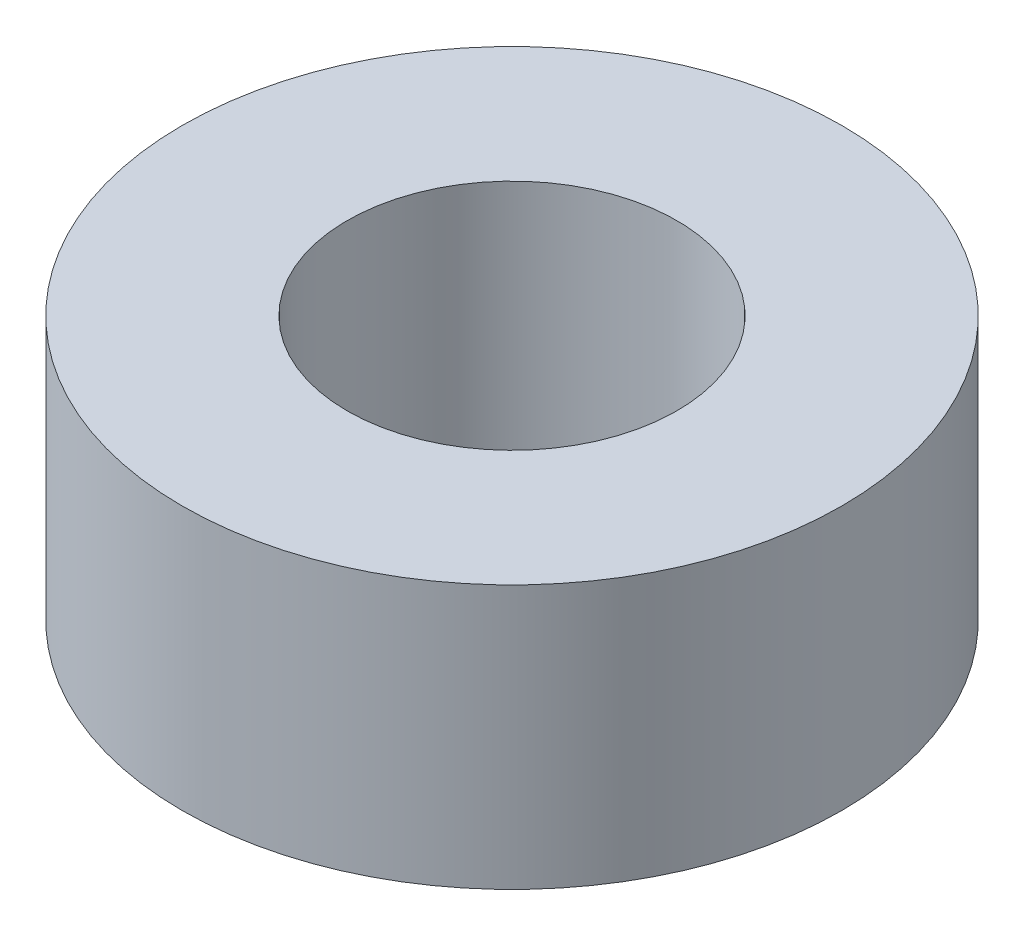
from build123d import *

# Parameters (mm, degrees)
SKETCH2_R           = 5
SKETCH2_R_2         = 2.5
BOSS_EXTRUDE1_DEPTH = 4


with BuildPart() as part:
    # Sketch2 → Boss-Extrude1 (new body)
    with BuildSketch(Plane(origin=(0, 0, 0), x_dir=(1, 0, 0), z_dir=(0, 1, 0))):
        Circle(SKETCH2_R)
        Circle(SKETCH2_R_2, mode=Mode.SUBTRACT)
    extrude(amount=BOSS_EXTRUDE1_DEPTH)


solid = part.part
